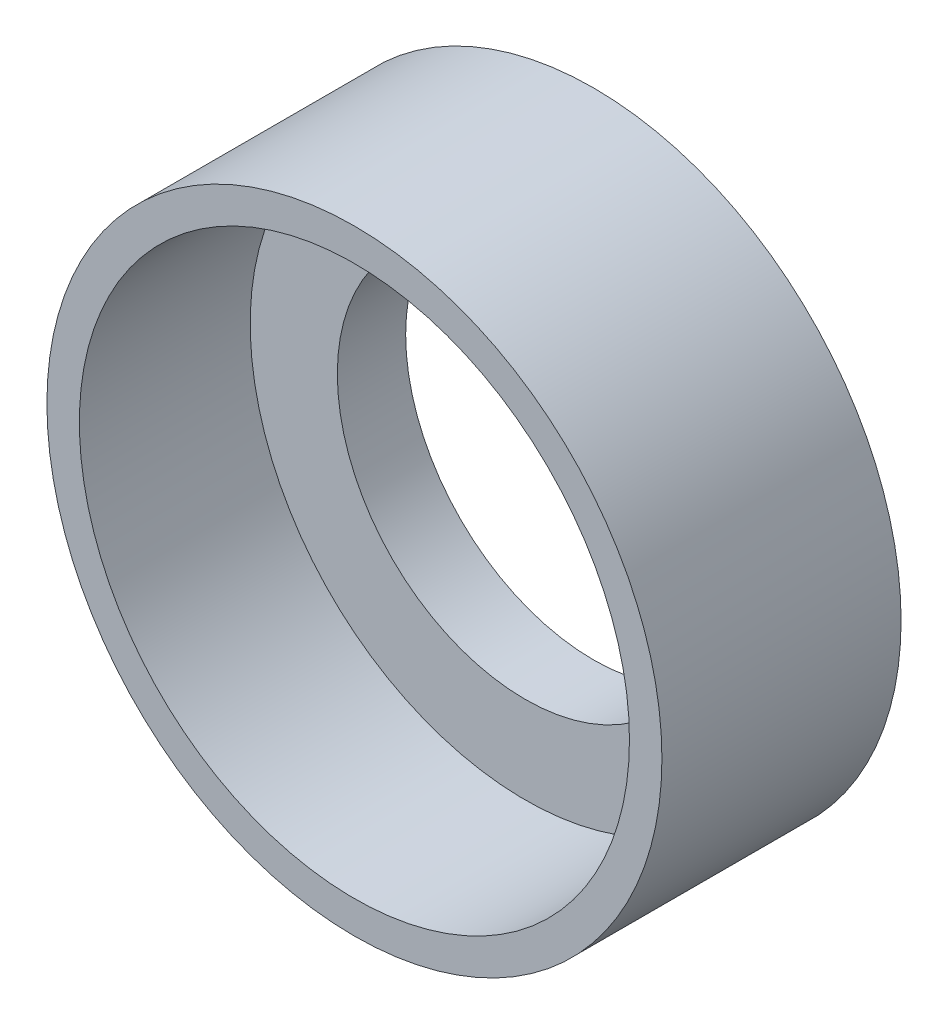
from build123d import *

# Parameters (mm, degrees)
SKETCH1_R           = 9
SKETCH1_R_2         = 5.5
BOSS_EXTRUDE1_DEPTH = 2
SKETCH2_R           = 9
SKETCH2_R_2         = 8.05
BOSS_EXTRUDE2_DEPTH = 5


with BuildPart() as part:
    # Sketch1 → Boss-Extrude1 (new body)
    with BuildSketch(Plane.XY):
        Circle(SKETCH1_R)
        Circle(SKETCH1_R_2, mode=Mode.SUBTRACT)
    extrude(amount=BOSS_EXTRUDE1_DEPTH)

    # Sketch2 → Boss-Extrude2 (add)
    with BuildSketch(Plane.XY.offset(2)):
        Circle(SKETCH2_R)
        Circle(SKETCH2_R_2, mode=Mode.SUBTRACT)
    extrude(amount=BOSS_EXTRUDE2_DEPTH)


solid = part.part
